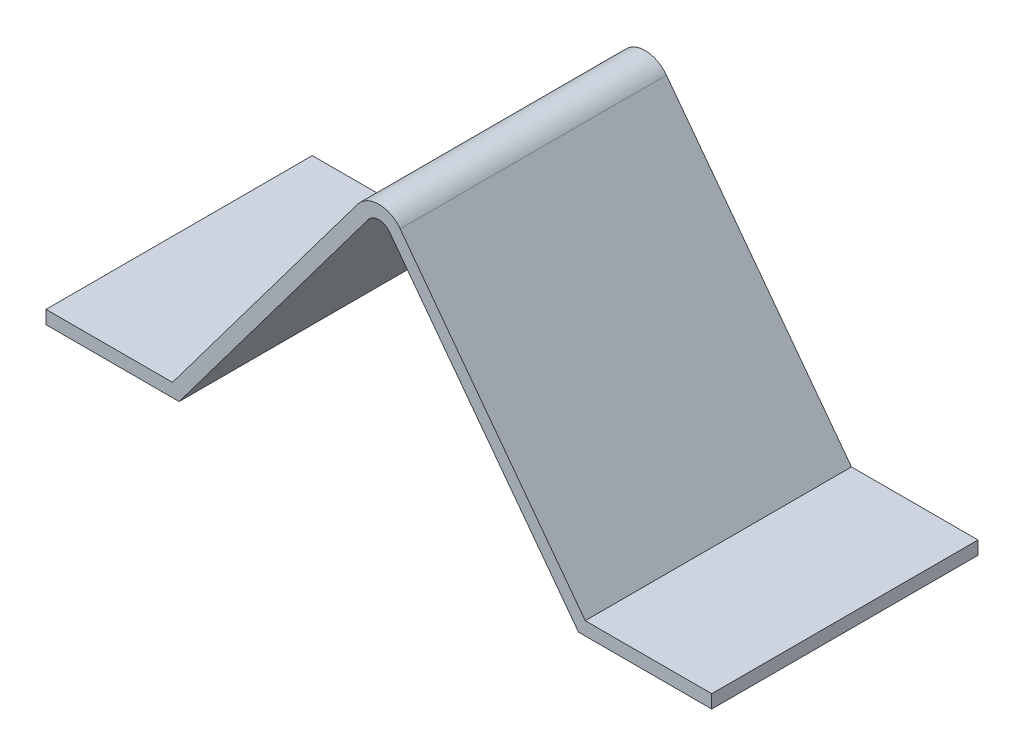
from build123d import *

# Parameters (mm, degrees)
EXTRUDE_1_DEPTH = 10
FILLET_1_R      = 1
FILLET_2_R      = 2


with BuildPart() as part:
    # 草图1 → 凸台-拉伸1 (new body, symmetric)
    with BuildSketch(Plane.XY):
        Polygon((-15, 0), (0, 20), (15, 0), (25, 0), (25, 1), (15.5, 1), (0, 21.666666667), (-15.5, 1), (-25, 1), (-25, 0), align=None)
    extrude(amount=EXTRUDE_1_DEPTH, both=True)

    # 圆角1
    fillet_1_edges = [part.edges().sort_by_distance(p)[0] for p in [
        (0, 20, 0),
    ]]
    fillet(fillet_1_edges, radius=FILLET_1_R)

    # 圆角2
    fillet_2_edges = [part.edges().sort_by_distance(p)[0] for p in [
        (0, 21.666666667, 0),
    ]]
    fillet(fillet_2_edges, radius=FILLET_2_R)


solid = part.part
